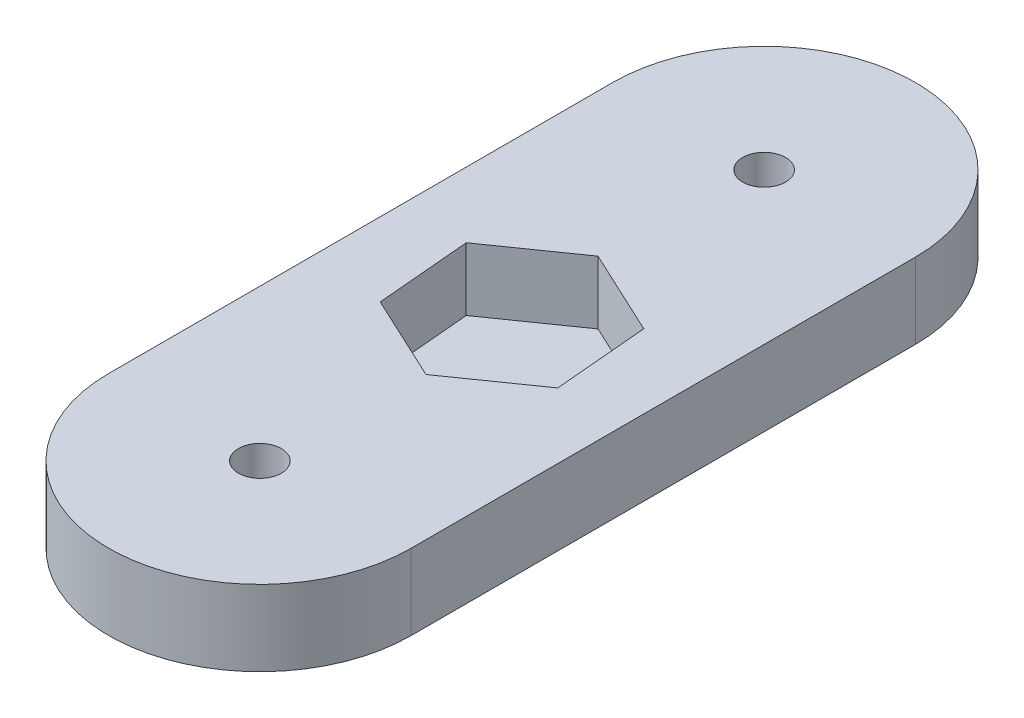
from build123d import *

# Parameters (mm, degrees)
SKETCH1_R           = 1.7
BOSS_EXTRUDE1_DEPTH = 6
CUT_EXTRUDE1_DEPTH  = 5


with BuildPart() as part:
    # Sketch1 → Boss-Extrude1 (new body)
    with BuildSketch(Plane(origin=(0, 0, 0), x_dir=(1, 0, 0), z_dir=(0, 1, 0))):
        with BuildLine():
            Line((-12, 0), (-12, 40))
            ThreePointArc((-12, 40), (0, 52), (12, 40))
            Line((12, 40), (12, 0))
            ThreePointArc((12, 0), (0, -12), (-12, 0))
        make_face()
        with Locations((0, 40)):
            Circle(SKETCH1_R, mode=Mode.SUBTRACT)
        Circle(SKETCH1_R, mode=Mode.SUBTRACT)
    extrude(amount=BOSS_EXTRUDE1_DEPTH)

    # Sketch2 → Cut-Extrude1 (cut)
    with BuildSketch(Plane(origin=(0, 6, 0), x_dir=(1, 0, 0), z_dir=(0, 1, 0))):
        Polygon((0.65415209, 12.523007398), (6.802341583, 16.828016027), (6.148189493, 24.305008629), (-0.65415209, 27.476992602), (-6.802341583, 23.171983973), (-6.148189493, 15.694991371), align=None)
    extrude(amount=-CUT_EXTRUDE1_DEPTH, mode=Mode.SUBTRACT)


solid = part.part
